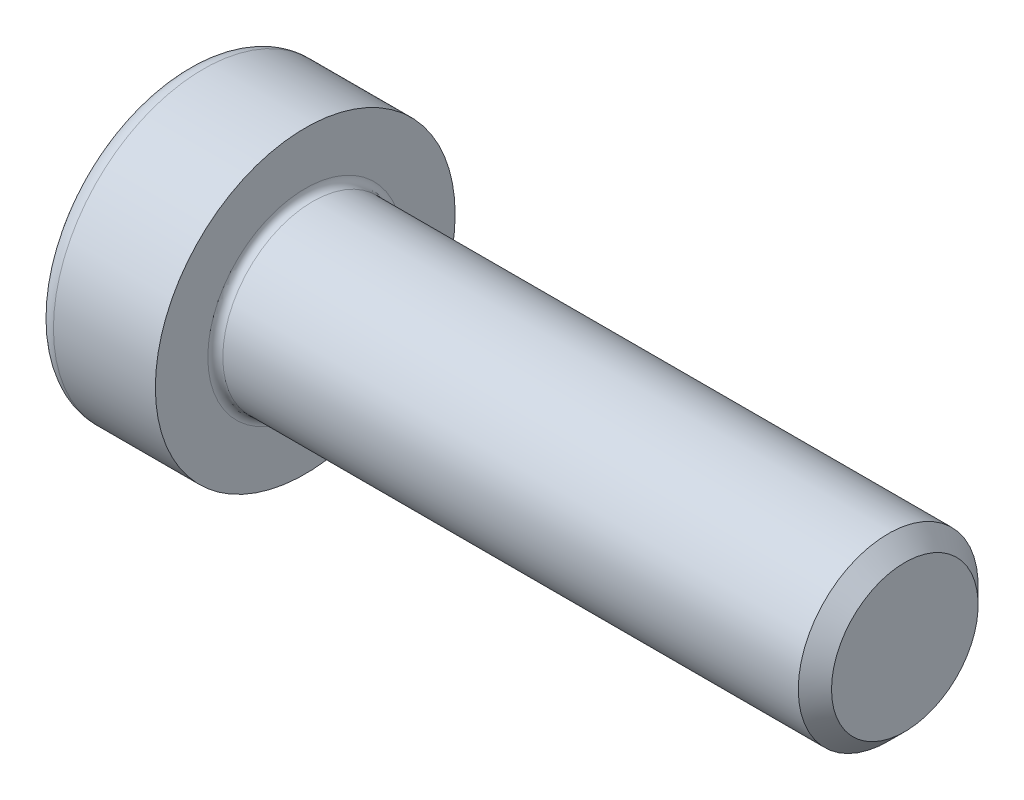
from build123d import *

# Parameters (mm, degrees)
FILLET1_R   = 0.25
FILLET2_R   = 0.6
HEX_2_DEPTH = 2.5


with BuildPart() as part:
    # BodySke → Base-Revolve (revolve)
    with BuildSketch(Plane.XY):
        Polygon((0, 0), (0, 5), (4, 5), (4, 3), (23.4455, 3), (24, 2.4455), (24, 0), align=None)
    revolve(axis=Axis((-31.75, 0, 0), (1, 0, 0)))

    # Fillet1
    fillet1_edges = [part.edges().sort_by_distance(p)[0] for p in [
        (4, -3, 0),
    ]]
    fillet(fillet1_edges, radius=FILLET1_R)

    # Fillet2
    fillet2_edges = [part.edges().sort_by_distance(p)[0] for p in [
        (0, -5, 0),
    ]]
    fillet(fillet2_edges, radius=FILLET2_R)

    # HexSke → Hex 2 (cut)
    with BuildSketch(Plane(origin=(0, 0, 0), x_dir=(0, 0.5, 0.866025404), z_dir=(-1, 0, 0))):
        Polygon((1.443375673, 2.5), (-1.443375673, 2.5), (-2.886751346, 0), (-1.443375673, -2.5), (1.443375673, -2.5), (2.886751346, 0), align=None)
    extrude(amount=-HEX_2_DEPTH, mode=Mode.SUBTRACT)

    # PilotSke → Hex-PreBroach (revolve, cut)
    with BuildSketch(Plane.XY):
        Polygon((0, 2.5), (2.5, 2.5), (3.077350269, 1.5), (5, 1.5), (5.866025404, 0), (0, 0), align=None)
    revolve(axis=Axis((0, 0, 0), (1, 0, 0)), mode=Mode.SUBTRACT)


solid = part.part
